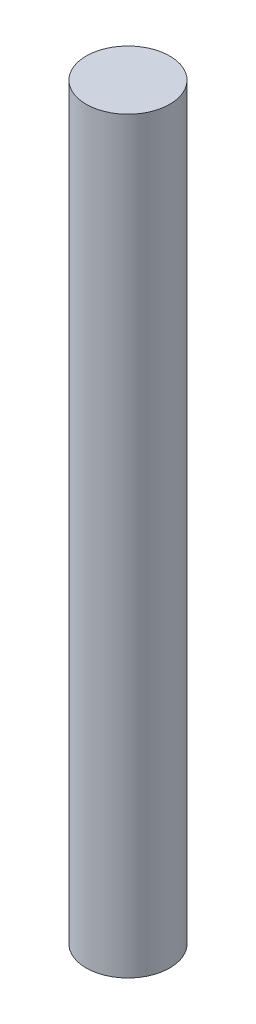
from build123d import *

# Parameters (mm, degrees)
SKETCH1_R           = 5.588
BOSS_EXTRUDE1_DEPTH = 100


with BuildPart() as part:
    # Sketch1 → Boss-Extrude1 (new body)
    with BuildSketch(Plane(origin=(0, 0, 0), x_dir=(1, 0, 0), z_dir=(0, 1, 0))):
        Circle(SKETCH1_R)
    extrude(amount=BOSS_EXTRUDE1_DEPTH)


solid = part.part
